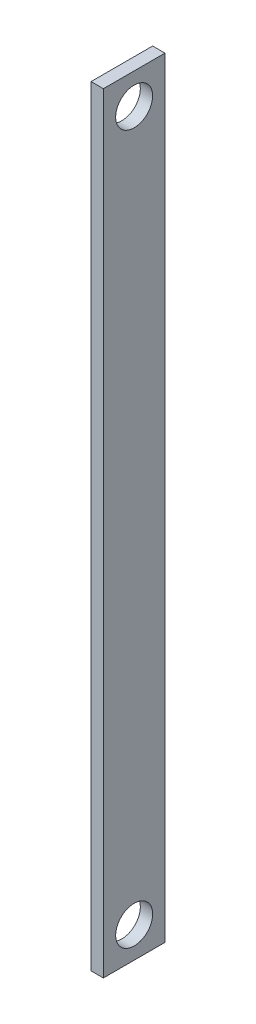
from build123d import *

# Parameters (mm, degrees)
SKETCH1_W           = 10
SKETCH1_H           = 125
BOSS_EXTRUDE1_DEPTH = 2
SKETCH3_R           = 3
CUT_EXTRUDE2_DEPTH  = 2


with BuildPart() as part:
    # Sketch1 → Boss-Extrude1 (new body)
    with BuildSketch(Plane(origin=(0, 0, 0), x_dir=(0, 0, -1), z_dir=(1, 0, 0))):
        Rectangle(SKETCH1_W, SKETCH1_H)
    extrude(amount=BOSS_EXTRUDE1_DEPTH)

    # Sketch3 → Cut-Extrude2 (cut)
    with BuildSketch(Plane(origin=(2, 0, 0), x_dir=(0, 0, -1), z_dir=(1, 0, 0))):
        with Locations((0, 57.5)):
            Circle(SKETCH3_R)
        with Locations((0, -57.5)):
            Circle(SKETCH3_R)
    extrude(amount=-CUT_EXTRUDE2_DEPTH, mode=Mode.SUBTRACT)


solid = part.part
